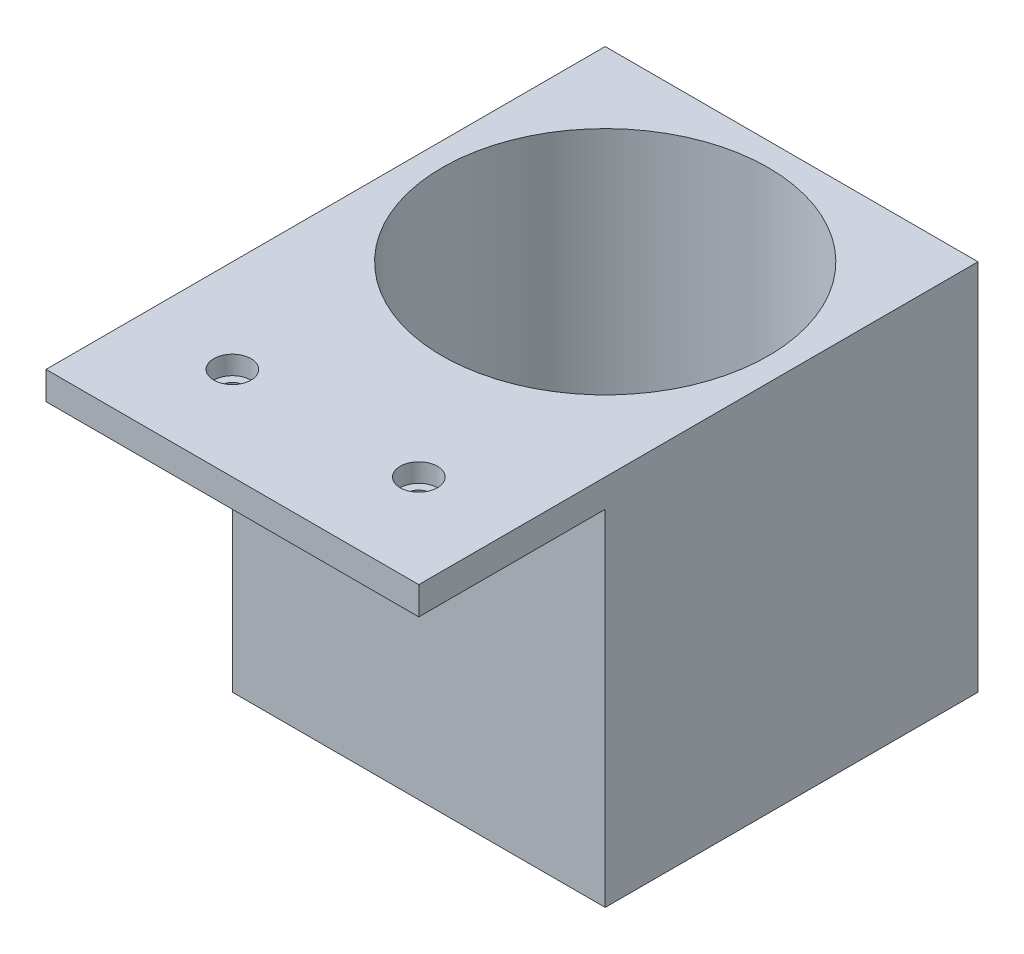
from build123d import *

# Parameters (mm, degrees)
EXTRUDE_THIN1_DEPTH            = 80
SKETCH4_W                      = 80
SKETCH4_H                      = 80
BOSS_EXTRUDE1_DEPTH            = 80
SKETCH5_R                      = 35
CUT_EXTRUDE1_DEPTH             = 1
CUT_EXTRUDE1_DEPTH_BACK        = 74
CBORE_FOR_M4_SHCS1_D           = 4.5
CBORE_FOR_M4_SHCS1_DEPTH       = 6
CBORE_FOR_M4_SHCS1_CBORE_D     = 8
CBORE_FOR_M4_SHCS1_CBORE_DEPTH = 4


with BuildPart() as part:
    # Sketch1 → Extrude-Thin1 (new body)
    with BuildSketch(Plane(origin=(0, 0, 0), x_dir=(0, 0, -1), z_dir=(1, 0, 0))):
        Polygon((0, -40), (0, 0), (-40, 0), (-40, 6), (6, 6), (6, -40), align=None)
    extrude(amount=EXTRUDE_THIN1_DEPTH)

    # Sketch4 → Boss-Extrude1 (add)
    with BuildSketch(Plane(origin=(0, 6, 0), x_dir=(1, 0, 0), z_dir=(0, 1, 0))):
        with Locations((40, 40)):
            Rectangle(SKETCH4_W, SKETCH4_H)
    extrude(amount=-BOSS_EXTRUDE1_DEPTH)

    # Sketch5 → Cut-Extrude1 (cut, two sides)
    with BuildSketch(Plane(origin=(0, 6, 0), x_dir=(1, 0, 0), z_dir=(0, 1, 0))) as cut_extrude1_sk:
        with Locations((40, 40)):
            Circle(SKETCH5_R)
    extrude(amount=CUT_EXTRUDE1_DEPTH, mode=Mode.SUBTRACT)
    extrude(cut_extrude1_sk.sketch, amount=-CUT_EXTRUDE1_DEPTH_BACK, mode=Mode.SUBTRACT)

    # CBORE for M4 SHCS1
    with Locations(Plane(origin=(0, 6, 0), x_dir=(1, 0, 0), z_dir=(0, 1, 0))):
        with Locations((60, -20), (20, -20)):
            CounterBoreHole(CBORE_FOR_M4_SHCS1_D / 2, CBORE_FOR_M4_SHCS1_CBORE_D / 2, CBORE_FOR_M4_SHCS1_CBORE_DEPTH, depth=CBORE_FOR_M4_SHCS1_DEPTH)


solid = part.part
